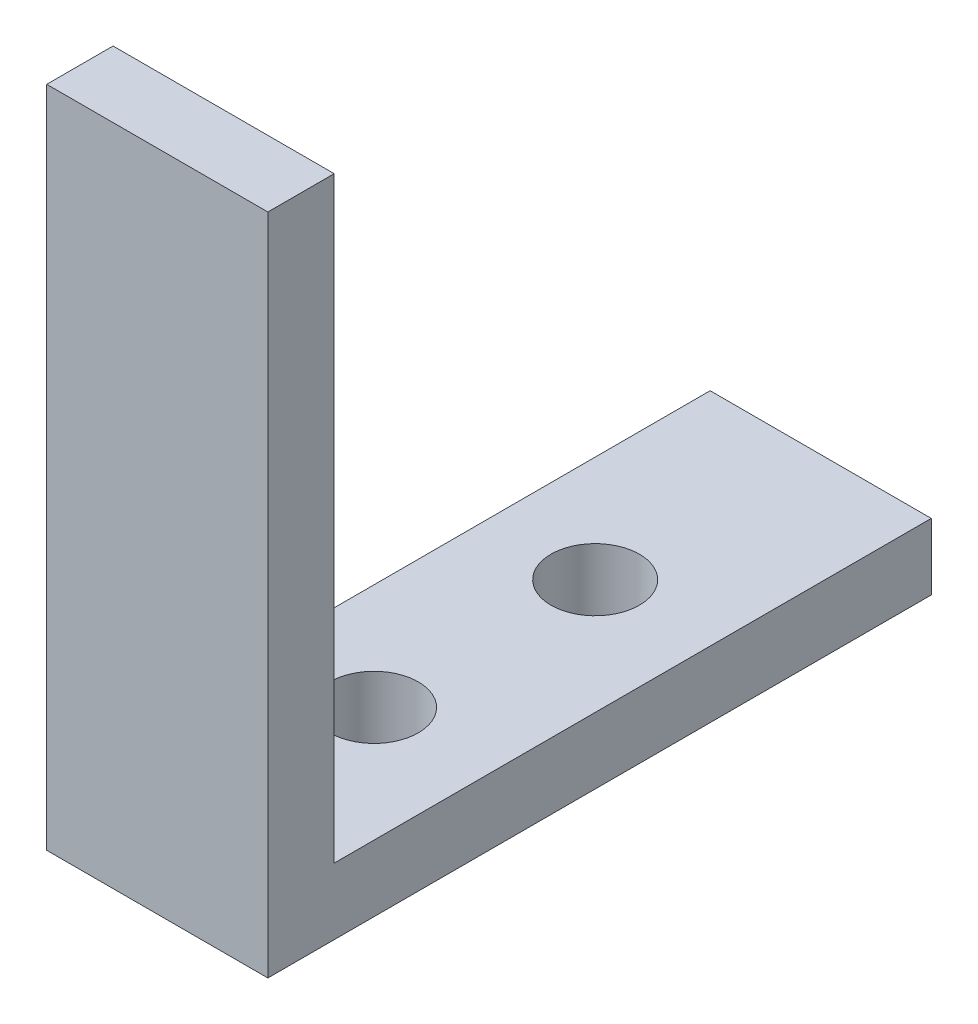
from build123d import *

# Parameters (mm, degrees)
BOSS_EXTRUDE1_DEPTH = 10
SKETCH2_R           = 2
CUT_EXTRUDE1_DEPTH  = 3


with BuildPart() as part:
    # Sketch1 → Boss-Extrude1 (new body)
    with BuildSketch(Plane(origin=(0, 0, 0), x_dir=(0, 0, -1), z_dir=(1, 0, 0))):
        Polygon((0, 30), (0, 0), (30, 0), (30, 3), (3, 3), (3, 30), align=None)
    extrude(amount=BOSS_EXTRUDE1_DEPTH)

    # Sketch2 → Cut-Extrude1 (cut)
    with BuildSketch(Plane(origin=(0, 3, 0), x_dir=(1, 0, 0), z_dir=(0, 1, 0))):
        with Locations((4.801961413, 10)):
            Circle(SKETCH2_R)
        with Locations((4.801961413, 20)):
            Circle(SKETCH2_R)
    extrude(amount=-CUT_EXTRUDE1_DEPTH, mode=Mode.SUBTRACT)


solid = part.part
